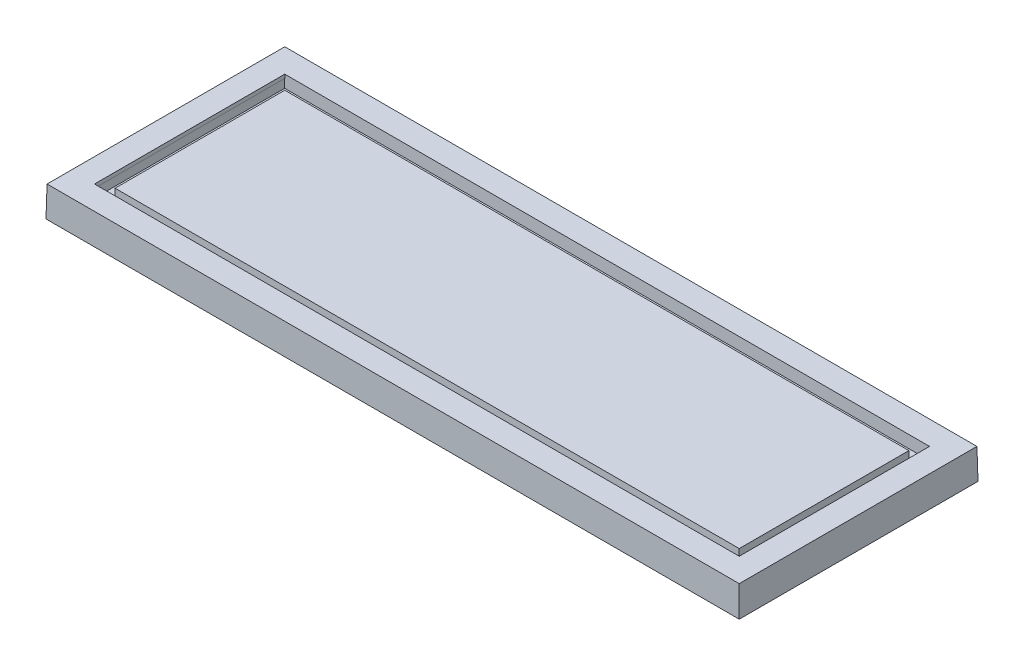
from build123d import *

# Parameters (mm, degrees)
SKETCH1_W           = 572
SKETCH1_H           = 197
BOSS_EXTRUDE1_DEPTH = 25
BOSS_EXTRUDE1_TAPER = 1
SKETCH2_W           = 532
SKETCH2_H           = 157
CUT_EXTRUDE1_DEPTH  = 3
CUT_EXTRUDE1_TAPER  = 1
SKETCH4_W           = 532
SKETCH4_H           = 156.89526961
SKETCH4_W_2         = 515
SKETCH4_H_2         = 140
CUT_EXTRUDE2_DEPTH  = 7
CUT_EXTRUDE2_TAPER  = 1


with BuildPart() as part:
    # Sketch1 → Boss-Extrude1 (new body)
    with BuildSketch(Plane(origin=(0, 0, 0), x_dir=(1, 0, 0), z_dir=(0, 1, 0))):
        Rectangle(SKETCH1_W, SKETCH1_H)
    extrude(amount=BOSS_EXTRUDE1_DEPTH, taper=BOSS_EXTRUDE1_TAPER)

    # Sketch2 → Cut-Extrude1 (cut)
    with BuildSketch(Plane(origin=(0, 25, 0), x_dir=(1, 0, 0), z_dir=(0, 1, 0))):
        Rectangle(SKETCH2_W, SKETCH2_H)
    extrude(amount=-CUT_EXTRUDE1_DEPTH, taper=CUT_EXTRUDE1_TAPER, mode=Mode.SUBTRACT)

    # Sketch4 → Cut-Extrude2 (cut)
    with BuildSketch(Plane(origin=(0, 22, 0), x_dir=(1, 0, 0), z_dir=(0, 1, 0))):
        Rectangle(SKETCH4_W, SKETCH4_H)
        Rectangle(SKETCH4_W_2, SKETCH4_H_2, mode=Mode.SUBTRACT)
    extrude(amount=-CUT_EXTRUDE2_DEPTH, taper=CUT_EXTRUDE2_TAPER, mode=Mode.SUBTRACT)


solid = part.part
